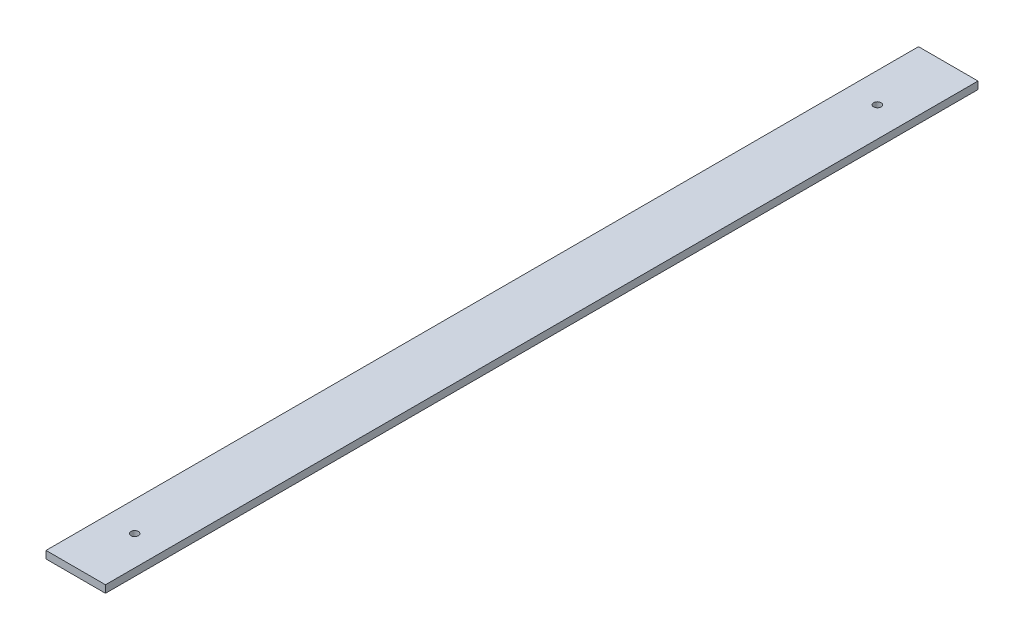
from build123d import *

# Parameters (mm, degrees)
SKETCH4_W             = 200
SKETCH4_H             = 2933.573874127
SKETCH4_R             = 12.5
BOSS_EXTRUDE1_DEPTH   = 25
SKETCH4_H_2           = 2891.000919938
BOSS_EXTRUDE1_2_DEPTH = 25
SKETCH4_H_3           = 2656.8496719
BOSS_EXTRUDE1_3_DEPTH = 25
SKETCH4_H_4           = 2167.26069873
BOSS_EXTRUDE1_4_DEPTH = 25
SKETCH4_H_5           = 1693.636583381
BOSS_EXTRUDE1_5_DEPTH = 25
SKETCH5_W             = 5252.2870397
SKETCH5_H             = 5093.660921052
CUT_EXTRUDE3_DEPTH    = 26


with BuildPart() as part:
    # Sketch4 → Boss-Extrude1 (new body)
    with BuildSketch(Plane(origin=(0, 0, 0), x_dir=(1, 0, 0), z_dir=(0, 1, 0))):
        with Locations((23132.944645813, -11409.369811035)):
            Rectangle(SKETCH4_W, SKETCH4_H)
        with Locations((23132.944645813, -12678.089615367)):
            Circle(SKETCH4_R, mode=Mode.SUBTRACT)
        with Locations((23132.944645813, -10181.030459334)):
            Circle(SKETCH4_R, mode=Mode.SUBTRACT)
    extrude(amount=BOSS_EXTRUDE1_DEPTH)


with BuildPart() as body_2:
    # Sketch4 → Boss-Extrude1 2 (new body)
    with BuildSketch(Plane(origin=(0, 0, 0), x_dir=(1, 0, 0), z_dir=(0, 1, 0))):
        with Locations((22032.944645813, -11388.083333941)):
            Rectangle(SKETCH4_W, SKETCH4_H_2)
        with Locations((22032.944645813, -12621.228285175)):
            Circle(SKETCH4_R, mode=Mode.SUBTRACT)
        with Locations((22032.944645813, -10181.030459334)):
            Circle(SKETCH4_R, mode=Mode.SUBTRACT)
    extrude(amount=BOSS_EXTRUDE1_2_DEPTH)


with BuildPart() as body_3:
    # Sketch4 → Boss-Extrude1 3 (new body)
    with BuildSketch(Plane(origin=(0, 0, 0), x_dir=(1, 0, 0), z_dir=(0, 1, 0))):
        with Locations((20832.944645813, -11271.007709922)):
            Rectangle(SKETCH4_W, SKETCH4_H_3)
        with Locations((20832.944645813, -12348.754240871)):
            Circle(SKETCH4_R, mode=Mode.SUBTRACT)
        with Locations((20832.944645813, -10181.030459334)):
            Circle(SKETCH4_R, mode=Mode.SUBTRACT)
    extrude(amount=BOSS_EXTRUDE1_3_DEPTH)


with BuildPart() as body_4:
    # Sketch4 → Boss-Extrude1 4 (new body)
    with BuildSketch(Plane(origin=(0, 0, 0), x_dir=(1, 0, 0), z_dir=(0, 1, 0))):
        with Locations((19632.944645813, -11026.213223337)):
            Rectangle(SKETCH4_W, SKETCH4_H_4)
        with Locations((19632.944645813, -11826.915448153)):
            Circle(SKETCH4_R, mode=Mode.SUBTRACT)
        with Locations((19632.944645813, -10181.030459334)):
            Circle(SKETCH4_R, mode=Mode.SUBTRACT)
    extrude(amount=BOSS_EXTRUDE1_4_DEPTH)


with BuildPart() as body_5:
    # Sketch4 → Boss-Extrude1 5 (new body)
    with BuildSketch(Plane(origin=(0, 0, 0), x_dir=(1, 0, 0), z_dir=(0, 1, 0))):
        with Locations((18802.944645813, -10789.401165663)):
            Rectangle(SKETCH4_W, SKETCH4_H_5)
        with Locations((18802.944645813, -11283.669778774)):
            Circle(SKETCH4_R, mode=Mode.SUBTRACT)
        with Locations((18802.944645813, -10181.030459334)):
            Circle(SKETCH4_R, mode=Mode.SUBTRACT)
    extrude(amount=BOSS_EXTRUDE1_5_DEPTH)


with BuildPart() as cut_extrude3_tool:
    # Sketch5 → Cut-Extrude3 (new body, through all)
    with BuildSketch(Plane(origin=(0, 0, 0), x_dir=(1, 0, 0), z_dir=(0, 1, 0))):
        with Locations((19839.936690978, -11321.244189564)):
            Rectangle(SKETCH5_W, SKETCH5_H)
    extrude(amount=CUT_EXTRUDE3_DEPTH)


with BuildPart() as body_2_1:
    add(body_2.part)

    # Cut-Extrude3: cut by cut_extrude3_tool
    add(cut_extrude3_tool.part, mode=Mode.SUBTRACT)


with BuildPart() as body_3_1:
    add(body_3.part)

    # Cut-Extrude3: cut by cut_extrude3_tool
    add(cut_extrude3_tool.part, mode=Mode.SUBTRACT)


with BuildPart() as body_4_1:
    add(body_4.part)

    # Cut-Extrude3: cut by cut_extrude3_tool
    add(cut_extrude3_tool.part, mode=Mode.SUBTRACT)


with BuildPart() as body_5_1:
    add(body_5.part)

    # Cut-Extrude3: cut by cut_extrude3_tool
    add(cut_extrude3_tool.part, mode=Mode.SUBTRACT)


solid = part.part
